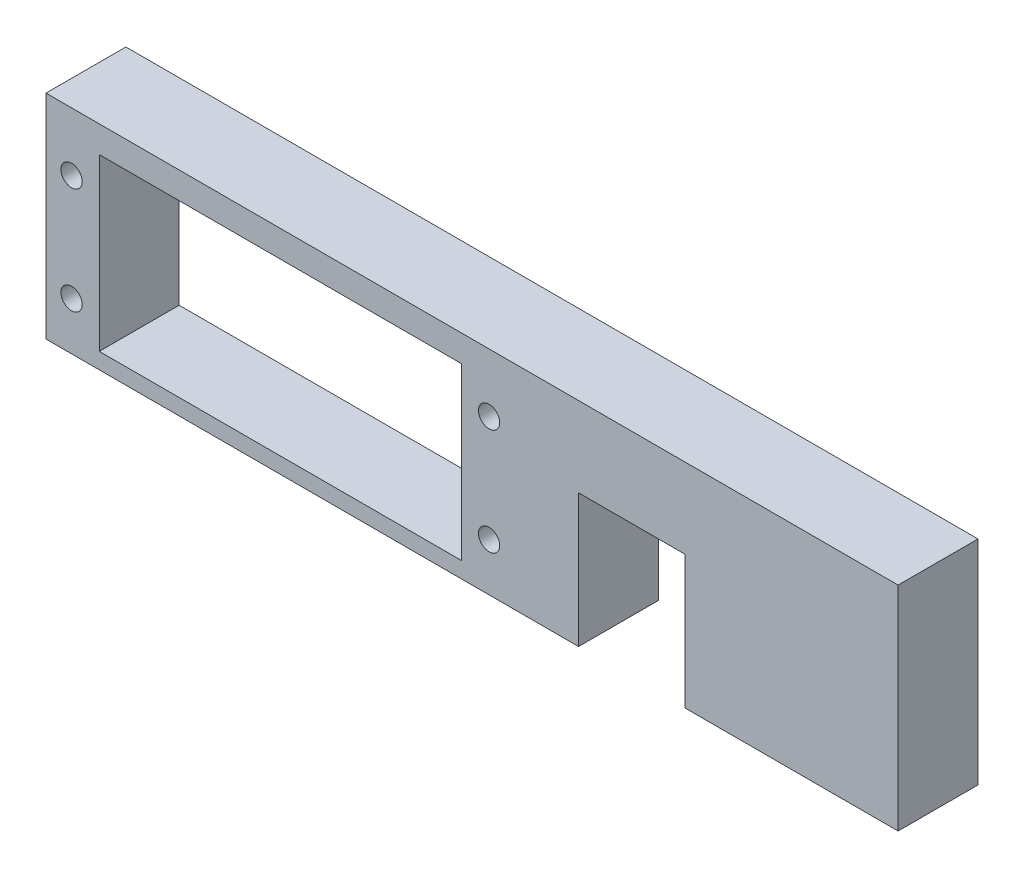
from build123d import *

# Parameters (mm, degrees)
SKETCH1_R           = 1.27
SKETCH1_W           = 43.18
SKETCH1_H           = 20.32
BOSS_EXTRUDE1_DEPTH = 9.525
SKETCH2_R           = 1.7272
CUT_EXTRUDE1_DEPTH  = 12.7


with BuildPart() as part:
    # Sketch1 → Boss-Extrude1 (new body)
    with BuildSketch(Plane.XY):
        Polygon((0, 0), (63.5, 0), (63.5, 15.875), (76.2, 15.875), (76.2, 0), (101.6, 0), (101.6, 25.4), (0, 25.4), align=None)
        with Locations((3.048, 18.415)):
            Circle(SKETCH1_R, mode=Mode.SUBTRACT)
        with Locations((3.048, 5.715)):
            Circle(SKETCH1_R, mode=Mode.SUBTRACT)
        with Locations((52.832, 18.415)):
            Circle(SKETCH1_R, mode=Mode.SUBTRACT)
        with Locations((52.832, 5.715)):
            Circle(SKETCH1_R, mode=Mode.SUBTRACT)
        with Locations((27.94, 12.065)):
            Rectangle(SKETCH1_W, SKETCH1_H, mode=Mode.SUBTRACT)
    extrude(amount=BOSS_EXTRUDE1_DEPTH)

    # Sketch2 → Cut-Extrude1 (cut)
    with BuildSketch(Plane.XZ):
        with Locations((60.2488, 4.7625)):
            Circle(SKETCH2_R)
        with Locations((79.2988, 4.7625)):
            Circle(SKETCH2_R)
    extrude(amount=-CUT_EXTRUDE1_DEPTH, mode=Mode.SUBTRACT)


solid = part.part
